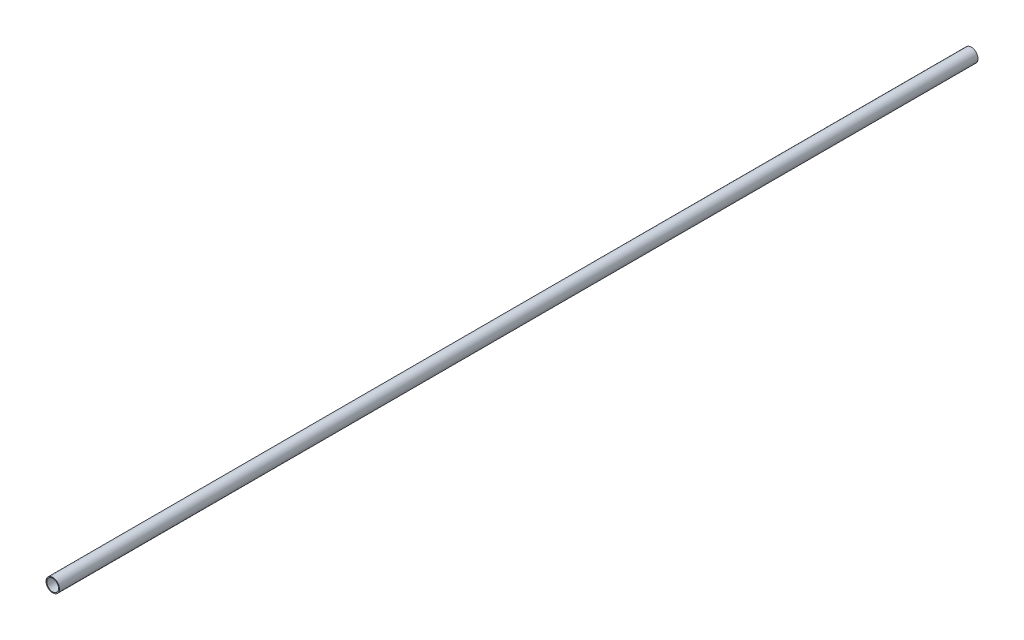
from build123d import *

# Parameters (mm, degrees)
SKETCH3_R                = 10.922
SKETCH3_R_2              = 9.525
BOSS_EXTRUDE1_DEPTH      = 742.95
BOSS_EXTRUDE1_DEPTH_BACK = 742.95


with BuildPart() as part:
    # Sketch3 → Boss-Extrude1 (new body, two sides)
    with BuildSketch(Plane.XY) as boss_extrude1_sk:
        Circle(SKETCH3_R)
        Circle(SKETCH3_R_2, mode=Mode.SUBTRACT)
    extrude(amount=BOSS_EXTRUDE1_DEPTH)
    extrude(boss_extrude1_sk.sketch, amount=-BOSS_EXTRUDE1_DEPTH_BACK)


solid = part.part
